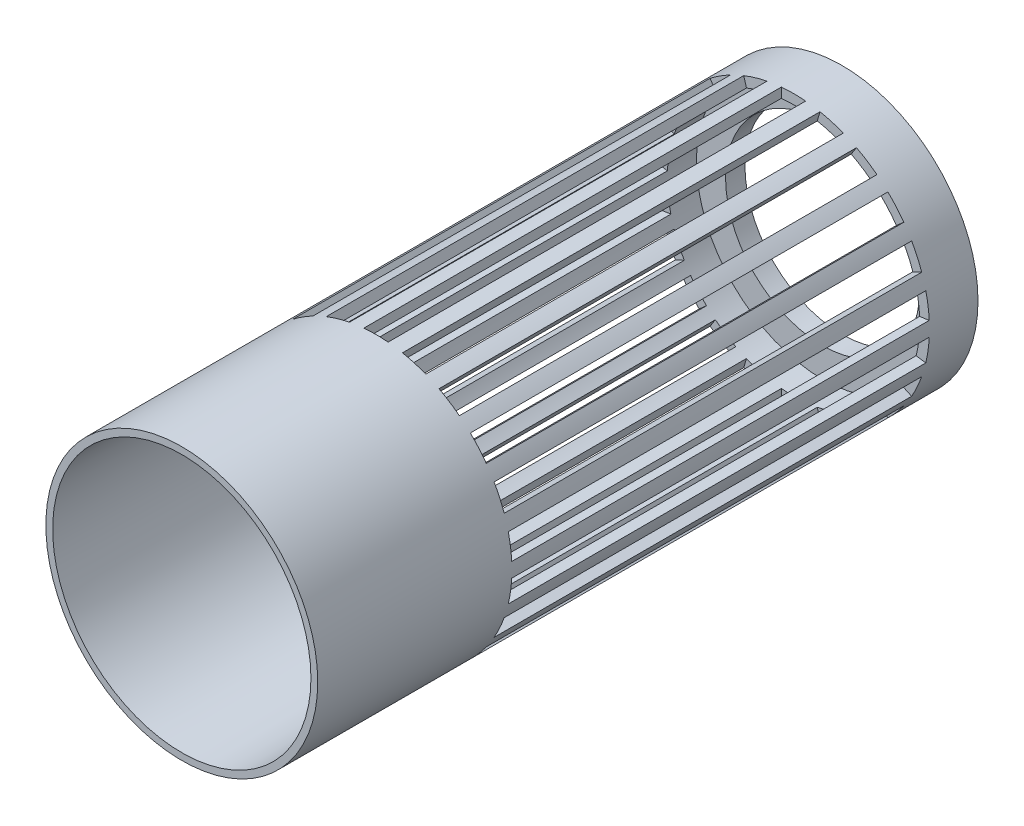
from build123d import *

# Parameters (mm, degrees)
SKETCH_1_R               = 7
SKETCH_1_R_2             = 6.5
EXTRUDE_1_DEPTH          = 33
EXTRUDE_START            = -1
SKETCH_1_3_R             = 7
EXTRUDE_2_DEPTH          = 1
SKETCH_9_W               = 1.25
SKETCH_9_H               = 21.5
CUT_EXTRUDE_2_DEPTH      = 35.452866354
PATTERN_CIRCULAR_1_COUNT = 11
CUT_EXTRUDE_3_DEPTH      = 36.411862419
CUT_EXTRUDE_3_DEPTH_BACK = 36.411862419
SKETCH_11_R              = 5


with BuildPart() as part:
    # 스케치1 → 보스-돌출1 (new body)
    with BuildSketch(Plane.XY):
        Circle(SKETCH_1_R)
        Circle(SKETCH_1_R_2, mode=Mode.SUBTRACT)
    extrude(amount=EXTRUDE_1_DEPTH)

    # 스케치1<3> → 보스-돌출2 (add)
    with BuildSketch(Plane.XY.offset(EXTRUDE_START)):
        Circle(SKETCH_1_3_R)
    extrude(amount=EXTRUDE_2_DEPTH)

    # 스케치9 → 컷-돌출2 (cut, symmetric)
    with BuildSketch(Plane(origin=(0, 0, 0), x_dir=(1, 0, 0), z_dir=(0, 1, 0))):
        with Locations((0, -12.25)):
            Rectangle(SKETCH_9_W, SKETCH_9_H)
    cut_extrude_2 = extrude(amount=CUT_EXTRUDE_2_DEPTH, both=True, mode=Mode.SUBTRACT)

    # 원형 패턴1: 컷-돌출2 ×11 about axis
    pattern_circular_1_axis = Axis((0, 0, -1), (0, 0, -1))
    for i in range(1, PATTERN_CIRCULAR_1_COUNT):
        add(cut_extrude_2.rotate(pattern_circular_1_axis, i * 360 / PATTERN_CIRCULAR_1_COUNT), mode=Mode.SUBTRACT)

    # 컷-스윕1: sweep along a curve in space
    with BuildLine() as sweep_1_path:
        ThreePointArc((6.5, 0, 33), (4.596194078, 4.596194078, 33), (0, 6.5, 33))
        ThreePointArc((0, 6.5, 33), (-4.596194078, 4.596194078, 33), (-6.5, 0, 33))
        ThreePointArc((-6.5, 0, 33), (-4.596194078, -4.596194078, 33), (0, -6.5, 33))
        ThreePointArc((0, -6.5, 33), (4.596194078, -4.596194078, 33), (6.5, 0, 33))
    # 스케치10 → 컷-스윕1 (sweep, cut)
    with BuildSketch(Plane(origin=(0, 0, 0), x_dir=(1, 0, 0), z_dir=(0, 1, 0))):
        Polygon((6.5, -33), (6.5, -23), (6.65, -33), align=None)
    sweep(path=sweep_1_path.line, mode=Mode.SUBTRACT)

    # 스케치11 → 컷-돌출3 (cut, two sides: drawn at the far end of the back side and taken through both)
    with BuildSketch(Plane(origin=(0, 0, -1), x_dir=(-1, 0, 0), z_dir=(0, 0, -1)).offset(-CUT_EXTRUDE_3_DEPTH_BACK)):
        Circle(SKETCH_11_R)
    extrude(amount=CUT_EXTRUDE_3_DEPTH + CUT_EXTRUDE_3_DEPTH_BACK, mode=Mode.SUBTRACT)


solid = part.part
